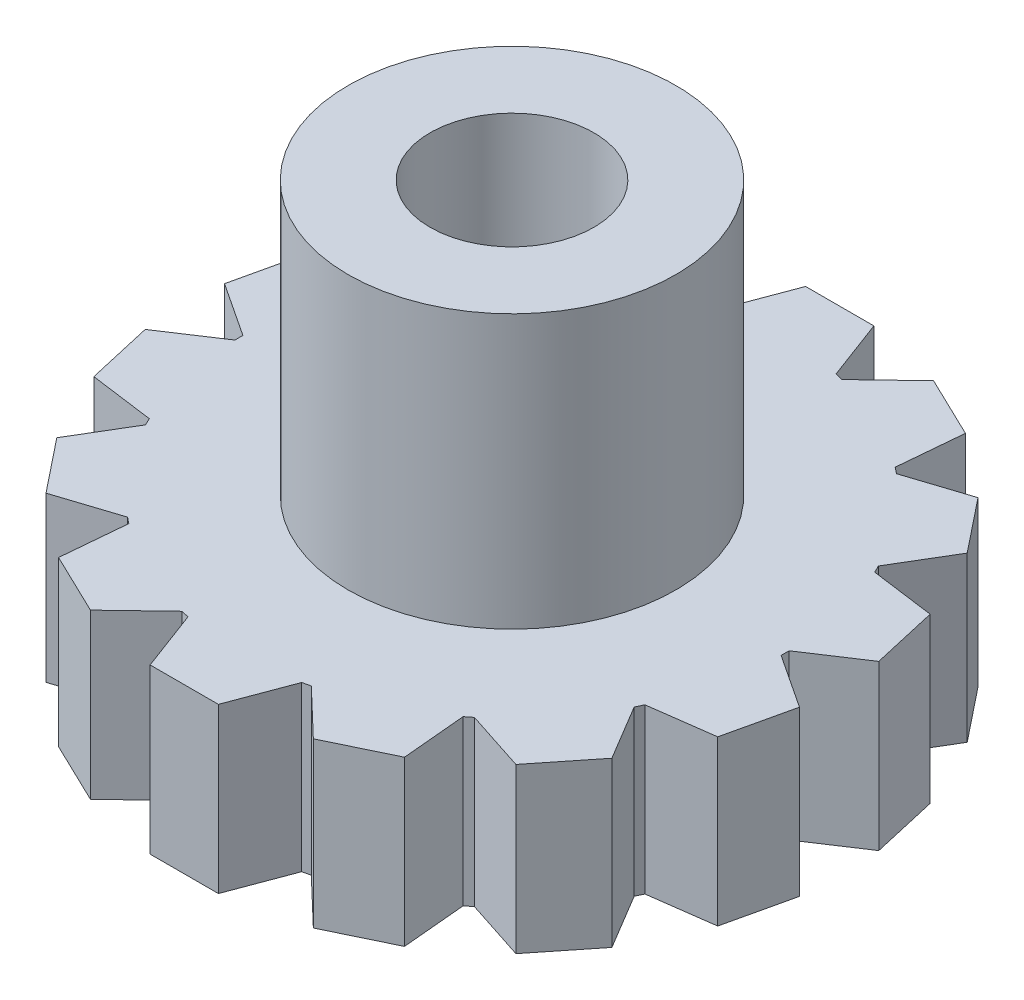
from build123d import *

# Parameters (mm, degrees)
SKETCH1_R           = 10
SKETCH1_R_2         = 3.15
BOSS_EXTRUDE1_DEPTH = 6
SKETCH2_R           = 6
SKETCH2_R_2         = 3
BOSS_EXTRUDE2_DEPTH = 10
BOSS_EXTRUDE3_DEPTH = 6


with BuildPart() as part:
    # Sketch1 → Boss-Extrude1 (new body)
    with BuildSketch(Plane(origin=(0, 0, 0), x_dir=(1, 0, 0), z_dir=(0, 1, 0))):
        Circle(SKETCH1_R)
        Circle(SKETCH1_R_2, mode=Mode.SUBTRACT)
    extrude(amount=BOSS_EXTRUDE1_DEPTH)

    # Sketch2 → Boss-Extrude2 (add)
    with BuildSketch(Plane(origin=(0, 6, 0), x_dir=(1, 0, 0), z_dir=(0, 1, 0))):
        Circle(SKETCH2_R)
        Circle(SKETCH2_R_2, mode=Mode.SUBTRACT)
    extrude(amount=BOSS_EXTRUDE2_DEPTH)

    # Sketch3 → Boss-Extrude3 (add)
    with BuildSketch(Plane(origin=(0, 6, 0), x_dir=(1, 0, 0), z_dir=(0, 1, 0))):
        with BuildLine():
            Line((1.25, 12), (-1.25, 12))
            Line((-1.25, 12), (-2.082191781, 9.780821918))
            ThreePointArc((-2.082191781, 9.780821918), (0, 10), (2.082191781, 9.780821918))
            Line((2.082191781, 9.780821918), (1.25, 12))
        make_face()
        with BuildLine():
            ThreePointArc((-6.119729557, 7.908786895), (-4.338837391, 9.009688679), (-2.367749614, 9.715645206))
            Line((-2.367749614, 9.715645206), (-4.080393785, 11.353981089))
            Line((-4.080393785, 11.353981089), (-6.332815954, 10.269271741))
            Line((-6.332815954, 10.269271741), (-6.119729557, 7.908786895))
        make_face()
        with BuildLine():
            Line((4.080393785, 11.353981089), (2.367749614, 9.715645206))
            ThreePointArc((2.367749614, 9.715645206), (4.338837391, 9.009688679), (6.119729557, 7.908786895))
            Line((6.119729557, 7.908786895), (6.332815954, 10.269271741))
            Line((6.332815954, 10.269271741), (4.080393785, 11.353981089))
        make_face()
        with BuildLine():
            ThreePointArc((-8.945179841, 4.470319633), (-7.818314825, 6.234898019), (-6.348729159, 7.726165806))
            Line((-6.348729159, 7.726165806), (-8.602615537, 8.459166975))
            Line((-8.602615537, 8.459166975), (-10.161340042, 6.504588269))
            Line((-10.161340042, 6.504588269), (-8.945179841, 4.470319633))
        make_face()
        with BuildLine():
            Line((8.602615537, 8.459166975), (6.348729159, 7.726165806))
            ThreePointArc((6.348729159, 7.726165806), (7.818314825, 6.234898019), (8.945179841, 4.470319633))
            Line((8.945179841, 4.470319633), (10.161340042, 6.504588269))
            Line((10.161340042, 6.504588269), (8.602615537, 8.459166975))
        make_face()
        with BuildLine():
            ThreePointArc((-9.998927551, 0.146450742), (-9.749279122, 2.22520934), (-9.072265032, 4.206424514))
            Line((-9.072265032, 4.206424514), (-11.420983779, 3.888911098))
            Line((-11.420983779, 3.888911098), (-11.977286114, 1.451591317))
            Line((-11.977286114, 1.451591317), (-9.998927551, 0.146450742))
        make_face()
        with BuildLine():
            Line((11.420983779, 3.888911098), (9.072265032, 4.206424514))
            ThreePointArc((9.072265032, 4.206424514), (9.749279122, 2.22520934), (9.998927551, 0.146450742))
            Line((9.998927551, 0.146450742), (11.977286114, 1.451591317))
            Line((11.977286114, 1.451591317), (11.420983779, 3.888911098))
        make_face()
        with BuildLine():
            ThreePointArc((-9.072265032, -4.206424514), (-9.749279122, -2.22520934), (-9.998927551, -0.146450742))
            Line((-9.998927551, -0.146450742), (-11.977286114, -1.451591317))
            Line((-11.977286114, -1.451591317), (-11.420983779, -3.888911098))
            Line((-11.420983779, -3.888911098), (-9.072265032, -4.206424514))
        make_face()
        with BuildLine():
            Line((11.977286114, -1.451591317), (9.998927551, -0.146450742))
            ThreePointArc((9.998927551, -0.146450742), (9.749279122, -2.22520934), (9.072265032, -4.206424514))
            Line((9.072265032, -4.206424514), (11.420983779, -3.888911098))
            Line((11.420983779, -3.888911098), (11.977286114, -1.451591317))
        make_face()
        with BuildLine():
            ThreePointArc((-6.348729159, -7.726165806), (-7.818314825, -6.234898019), (-8.945179841, -4.470319633))
            Line((-8.945179841, -4.470319633), (-10.161340042, -6.504588269))
            Line((-10.161340042, -6.504588269), (-8.602615537, -8.459166975))
            Line((-8.602615537, -8.459166975), (-6.348729159, -7.726165806))
        make_face()
        with BuildLine():
            Line((10.161340042, -6.504588269), (8.945179841, -4.470319633))
            ThreePointArc((8.945179841, -4.470319633), (7.818314825, -6.234898019), (6.348729159, -7.726165806))
            Line((6.348729159, -7.726165806), (8.602615537, -8.459166975))
            Line((8.602615537, -8.459166975), (10.161340042, -6.504588269))
        make_face()
        with BuildLine():
            ThreePointArc((-2.367749614, -9.715645206), (-4.338837391, -9.009688679), (-6.119729557, -7.908786895))
            Line((-6.119729557, -7.908786895), (-6.332815954, -10.269271741))
            Line((-6.332815954, -10.269271741), (-4.080393785, -11.353981089))
            Line((-4.080393785, -11.353981089), (-2.367749614, -9.715645206))
        make_face()
        with BuildLine():
            Line((6.332815954, -10.269271741), (6.119729557, -7.908786895))
            ThreePointArc((6.119729557, -7.908786895), (4.338837391, -9.009688679), (2.367749614, -9.715645206))
            Line((2.367749614, -9.715645206), (4.080393785, -11.353981089))
            Line((4.080393785, -11.353981089), (6.332815954, -10.269271741))
        make_face()
        with BuildLine():
            ThreePointArc((2.082191781, -9.780821918), (0, -10), (-2.082191781, -9.780821918))
            Line((-2.082191781, -9.780821918), (-1.25, -12))
            Line((-1.25, -12), (1.25, -12))
            Line((1.25, -12), (2.082191781, -9.780821918))
        make_face()
    extrude(amount=-BOSS_EXTRUDE3_DEPTH)


solid = part.part
